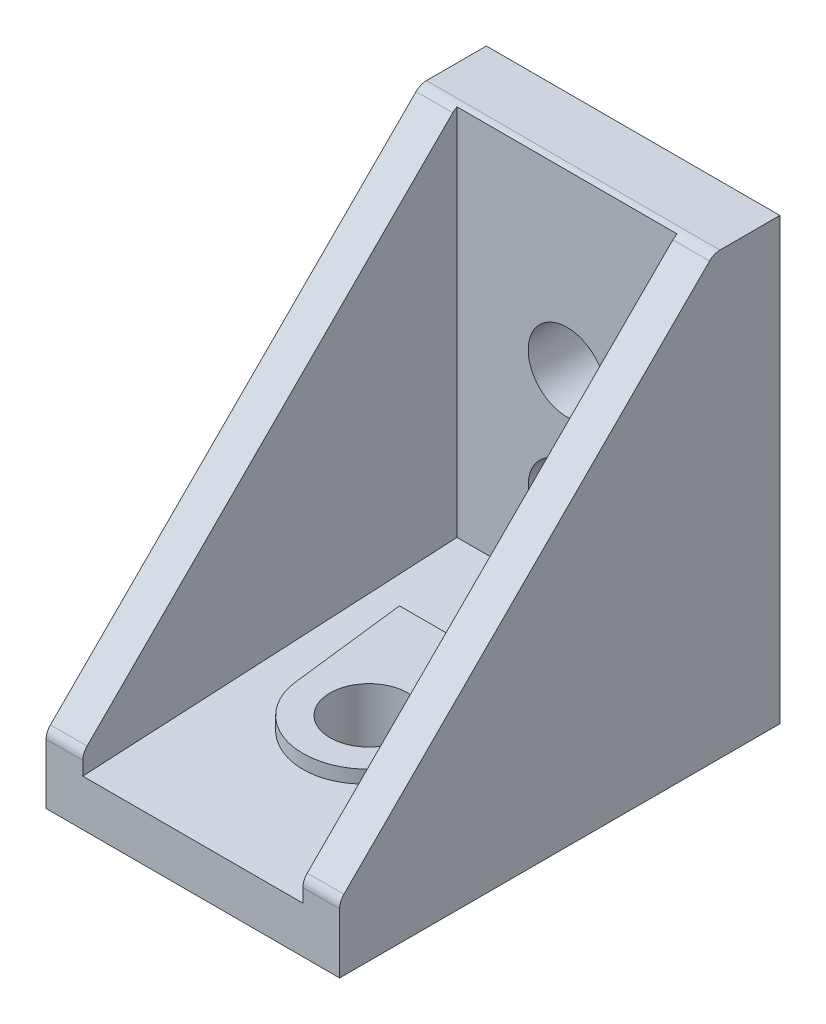
from build123d import *

# Parameters (mm, degrees)
BOSS_EXTRUDE1_DEPTH      = 10
BOSS_EXTRUDE1_DEPTH_BACK = 10
CUT_EXTRUDE1_DEPTH       = 7.5
CUT_EXTRUDE1_DEPTH_BACK  = 7.5
BOSS_EXTRUDE2_DEPTH      = 2.25
SKETCH4_R                = 2.65
CUT_EXTRUDE2_DEPTH       = 4.5
SKETCH5_R                = 2.65
CUT_EXTRUDE3_DEPTH       = 4.5
SKETCH6_R                = 2.65
CUT_EXTRUDE4_DEPTH       = 4.5
SKETCH7_W                = 20
SKETCH7_H                = 30
BOSS_EXTRUDE3_DEPTH      = 1
SKETCH8_W                = 20
SKETCH8_H                = 30
CUT_EXTRUDE5_DEPTH       = 1
SKETCH9_W                = 20
SKETCH9_H                = 30
BOSS_EXTRUDE4_DEPTH      = 1
SKETCH10_W               = 20
SKETCH10_H               = 30
CUT_EXTRUDE6_DEPTH       = 1


with BuildPart() as part:
    # Sketch1 → Boss-Extrude1 (new body, two sides)
    with BuildSketch(Plane(origin=(0, 0, 0), x_dir=(0, 0, -1), z_dir=(1, 0, 0))) as boss_extrude1_sk:
        with BuildLine():
            Line((-30, 0), (0, 0))
            Line((0, 0), (0, 30))
            Line((0, 30), (-4.085786438, 30))
            ThreePointArc((-4.085786438, 30), (-4.46846987, 29.923879533), (-4.792893219, 29.707106781))
            Line((-4.792893219, 29.707106781), (-29.707106781, 4.792893219))
            ThreePointArc((-29.707106781, 4.792893219), (-29.923879533, 4.46846987), (-30, 4.085786438))
            Line((-30, 4.085786438), (-30, 0))
        make_face()
    extrude(amount=BOSS_EXTRUDE1_DEPTH)
    extrude(boss_extrude1_sk.sketch, amount=-BOSS_EXTRUDE1_DEPTH_BACK)

    # Sketch2 → Cut-Extrude1 (cut, two sides)
    with BuildSketch(Plane(origin=(0, 0, 0), x_dir=(0, 0, -1), z_dir=(1, 0, 0))) as cut_extrude1_sk:
        Polygon((-34.5, 2.927766622), (-4.5, 4.5), (-4.5, 34.5), (-34.5, 34.5), align=None)
    extrude(amount=CUT_EXTRUDE1_DEPTH, mode=Mode.SUBTRACT)
    extrude(cut_extrude1_sk.sketch, amount=-CUT_EXTRUDE1_DEPTH_BACK, mode=Mode.SUBTRACT)

    # Sketch3 → Boss-Extrude2 (add)
    with BuildSketch(Plane(origin=(0, 4.5, 0), x_dir=(1, 0, 0), z_dir=(0, 1, 0))):
        with BuildLine():
            Line((-5.420884207, -10.5), (-4.4686916, -18.529901296))
            ThreePointArc((-4.4686916, -18.529901296), (0, -22.5), (4.4686916, -18.529901296))
            Line((4.4686916, -18.529901296), (5.420884207, -10.5))
            Line((5.420884207, -10.5), (-5.420884207, -10.5))
        make_face()
    extrude(amount=-BOSS_EXTRUDE2_DEPTH)

    # Sketch4 → Cut-Extrude2 (cut)
    with BuildSketch(Plane.XY):
        with Locations((0, 18)):
            Circle(SKETCH4_R)
    extrude(amount=CUT_EXTRUDE2_DEPTH, mode=Mode.SUBTRACT)

    # Sketch5 → Cut-Extrude3 (cut)
    with BuildSketch(Plane.XY):
        with Locations((0, 10)):
            Circle(SKETCH5_R)
    extrude(amount=CUT_EXTRUDE3_DEPTH, mode=Mode.SUBTRACT)

    # Sketch6 → Cut-Extrude4 (cut)
    with BuildSketch(Plane(origin=(0, 0, 0), x_dir=(1, 0, 0), z_dir=(0, 1, 0))):
        with Locations((0, -18)):
            Circle(SKETCH6_R)
    extrude(amount=CUT_EXTRUDE4_DEPTH, mode=Mode.SUBTRACT)

    # Sketch7 → Boss-Extrude3 (add)
    with BuildSketch(Plane(origin=(0, 0, 0), x_dir=(1, 0, 0), z_dir=(0, 1, 0))):
        with Locations((0, -15)):
            Rectangle(SKETCH7_W, SKETCH7_H)
    extrude(amount=-BOSS_EXTRUDE3_DEPTH)

    # Sketch8 → Cut-Extrude5 (cut)
    with BuildSketch(Plane(origin=(0, 0, 0), x_dir=(1, 0, 0), z_dir=(0, 1, 0))):
        with Locations((0, -15)):
            Rectangle(SKETCH8_W, SKETCH8_H)
        with BuildLine():
            Line((-2.7, -11), (2.7, -11))
            ThreePointArc((2.7, -11), (2.912132034, -10.912132034), (3, -10.7))
            Line((3, -10.7), (3, -5.3))
            ThreePointArc((3, -5.3), (2.912132034, -5.087867966), (2.7, -5))
            Line((2.7, -5), (-2.7, -5))
            ThreePointArc((-2.7, -5), (-2.912132034, -5.087867966), (-3, -5.3))
            Line((-3, -5.3), (-3, -10.7))
            ThreePointArc((-3, -10.7), (-2.912132034, -10.912132034), (-2.7, -11))
        make_face(mode=Mode.SUBTRACT)
        with BuildLine():
            Line((-2.7, -27), (2.7, -27))
            ThreePointArc((2.7, -27), (2.912132034, -26.912132034), (3, -26.7))
            Line((3, -26.7), (3, -24.3))
            ThreePointArc((3, -24.3), (2.912132034, -24.087867966), (2.7, -24))
            Line((2.7, -24), (-2.7, -24))
            ThreePointArc((-2.7, -24), (-2.912132034, -24.087867966), (-3, -24.3))
            Line((-3, -24.3), (-3, -26.7))
            ThreePointArc((-3, -26.7), (-2.912132034, -26.912132034), (-2.7, -27))
        make_face(mode=Mode.SUBTRACT)
    extrude(amount=-CUT_EXTRUDE5_DEPTH, mode=Mode.SUBTRACT)

    # Sketch9 → Boss-Extrude4 (add)
    with BuildSketch(Plane.XY):
        with Locations((0, 15)):
            Rectangle(SKETCH9_W, SKETCH9_H)
    extrude(amount=-BOSS_EXTRUDE4_DEPTH)

    # Sketch10 → Cut-Extrude6 (cut)
    with BuildSketch(Plane.XY):
        with Locations((0, 15)):
            Rectangle(SKETCH10_W, SKETCH10_H)
        with BuildLine():
            Line((0.5, 7), (2, 7))
            ThreePointArc((2, 7), (2.707106781, 7.292893219), (3, 8))
            Line((3, 8), (3, 9.5))
            Line((3, 9.5), (2.602402736, 9.5))
            ThreePointArc((2.602402736, 9.5), (1.87383297, 8.12616703), (0.5, 7.397597264))
            Line((0.5, 7.397597264), (0.5, 7))
        make_face(mode=Mode.SUBTRACT)
        with BuildLine():
            Line((0.5, 13), (0.5, 12.602402736))
            ThreePointArc((0.5, 12.602402736), (1.87383297, 11.87383297), (2.602402736, 10.5))
            Line((2.602402736, 10.5), (3, 10.5))
            Line((3, 10.5), (3, 12))
            ThreePointArc((3, 12), (2.707106781, 12.707106781), (2, 13))
            Line((2, 13), (0.5, 13))
        make_face(mode=Mode.SUBTRACT)
        with BuildLine():
            Line((-3, 9.5), (-3, 8))
            ThreePointArc((-3, 8), (-2.707106781, 7.292893219), (-2, 7))
            Line((-2, 7), (-0.5, 7))
            Line((-0.5, 7), (-0.5, 7.397597264))
            ThreePointArc((-0.5, 7.397597264), (-1.87383297, 8.12616703), (-2.602402736, 9.5))
            Line((-2.602402736, 9.5), (-3, 9.5))
        make_face(mode=Mode.SUBTRACT)
        with BuildLine():
            Line((-3, 10.5), (-2.602402736, 10.5))
            ThreePointArc((-2.602402736, 10.5), (-1.87383297, 11.87383297), (-0.5, 12.602402736))
            Line((-0.5, 12.602402736), (-0.5, 13))
            Line((-0.5, 13), (-2, 13))
            ThreePointArc((-2, 13), (-2.707106781, 12.707106781), (-3, 12))
            Line((-3, 12), (-3, 10.5))
        make_face(mode=Mode.SUBTRACT)
    extrude(amount=-CUT_EXTRUDE6_DEPTH, mode=Mode.SUBTRACT)


solid = part.part
